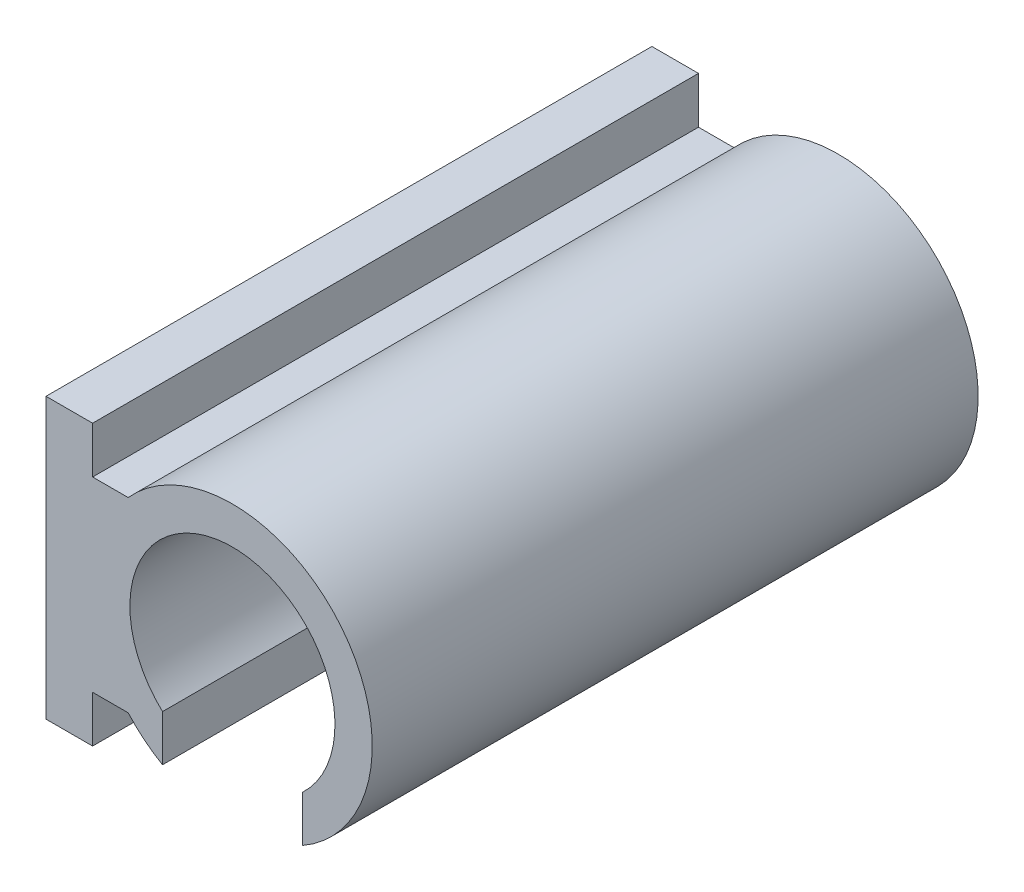
from build123d import *

# Parameters (mm, degrees)
SKETCH2_R           = 30
BOSS_EXTRUDE2_DEPTH = 130
SKETCH3_R           = 22
CUT_EXTRUDE1_DEPTH  = 131
CUT_EXTRUDE2_REACH  = 62
SKETCH4_W           = 30
SKETCH4_H           = 140
SKETCH5_W           = 130
SKETCH5_H           = 40
BOSS_EXTRUDE3_DEPTH = 7.63932
SKETCH6_W           = 130
SKETCH6_H           = 60
BOSS_EXTRUDE4_DEPTH = 10


with BuildPart() as part:
    # Sketch2 → Boss-Extrude2 (new body)
    with BuildSketch(Plane.XY):
        Circle(SKETCH2_R)
    extrude(amount=BOSS_EXTRUDE2_DEPTH)

    # Sketch3 → Cut-Extrude1 (cut, through all)
    with BuildSketch(Plane.XY.offset(130)):
        Circle(SKETCH3_R)
    extrude(amount=-CUT_EXTRUDE1_DEPTH, mode=Mode.SUBTRACT)

    # Sketch4 → Cut-Extrude2 (cut, up to next)
    with BuildSketch(Plane(origin=(0, -30, 0), x_dir=(1, 0, 0), z_dir=(0, 1, 0)), mode=Mode.PRIVATE) as cut_extrude2_sk1:
        with Locations((0, -70)):
            Rectangle(SKETCH4_W, SKETCH4_H)
    cut_extrude2_tool1 = extrude(cut_extrude2_sk1.sketch, amount=CUT_EXTRUDE2_REACH, mode=Mode.PRIVATE) & part.part
    add(cut_extrude2_tool1.solids().sort_by_distance((0, -30, 70))[0], mode=Mode.SUBTRACT)

    # Sketch5 → Boss-Extrude3 (add)
    with BuildSketch(Plane(origin=(-30, 0, 0), x_dir=(0, 0, -1), z_dir=(1, 0, 0))):
        with Locations((-65, 0)):
            Rectangle(SKETCH5_W, SKETCH5_H)
    extrude(amount=BOSS_EXTRUDE3_DEPTH)

    # Sketch6 → Boss-Extrude4 (add)
    with BuildSketch(Plane.ZY.offset(30)):
        with Locations((65, 0)):
            Rectangle(SKETCH6_W, SKETCH6_H)
    extrude(amount=BOSS_EXTRUDE4_DEPTH)


solid = part.part
